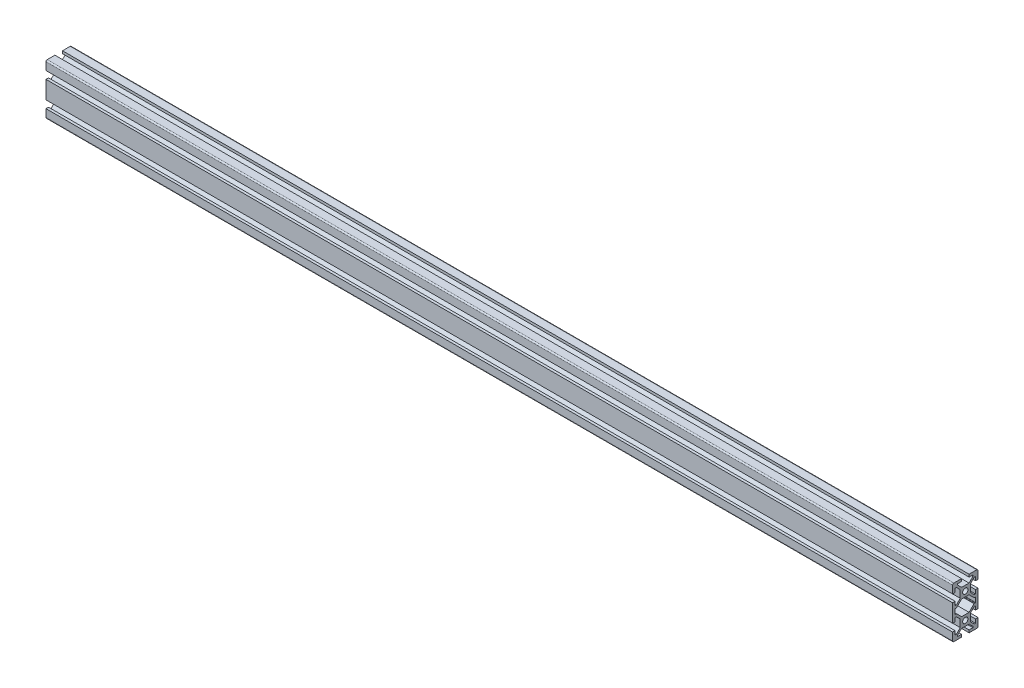
from build123d import *

# Parameters (mm, degrees)
SKETCH1_R           = 2.1
BOSS_EXTRUDE1_DEPTH = 714


with BuildPart() as part:
    # Sketch1 → Boss-Extrude1 (new body)
    with BuildSketch(Plane(origin=(0, 0, 0), x_dir=(0, 0, -1), z_dir=(1, 0, 0))):
        with BuildLine():
            Line((-10, -13), (-10, -19))
            ThreePointArc((-10, -19), (-9.707106781, -19.707106781), (-9, -20))
            Line((-9, -20), (-3, -20))
            Line((-3, -20), (-3, -18))
            Line((-3, -18), (-6, -18))
            Line((-6, -18), (-6, -17.060660172))
            Line((-6, -17.060660172), (-2.939339828, -14))
            Line((-2.939339828, -14), (2.939339828, -14))
            Line((2.939339828, -14), (6, -17.060660172))
            Line((6, -17.060660172), (6, -18))
            Line((6, -18), (3, -18))
            Line((3, -18), (3, -20))
            Line((3, -20), (9, -20))
            ThreePointArc((9, -20), (9.707106781, -19.707106781), (10, -19))
            Line((10, -19), (10, -13))
            Line((10, -13), (8, -13))
            Line((8, -13), (8, -16))
            Line((8, -16), (7.060660172, -16))
            Line((7.060660172, -16), (4, -12.939339828))
            Line((4, -12.939339828), (4, -7.060660172))
            Line((4, -7.060660172), (7.060660172, -4))
            Line((7.060660172, -4), (8, -4))
            Line((8, -4), (8, -7))
            Line((8, -7), (10, -7))
            Line((10, -7), (10, 7))
            Line((10, 7), (8, 7))
            Line((8, 7), (8, 4))
            Line((8, 4), (7.060660172, 4))
            Line((7.060660172, 4), (4, 7.060660172))
            Line((4, 7.060660172), (4, 12.939339828))
            Line((4, 12.939339828), (7.060660172, 16))
            Line((7.060660172, 16), (8, 16))
            Line((8, 16), (8, 13))
            Line((8, 13), (10, 13))
            Line((10, 13), (10, 19))
            ThreePointArc((10, 19), (9.707106781, 19.707106781), (9, 20))
            Line((9, 20), (3, 20))
            Line((3, 20), (3, 18))
            Line((3, 18), (6, 18))
            Line((6, 18), (6, 17.060660172))
            Line((6, 17.060660172), (2.939339828, 14))
            Line((2.939339828, 14), (-2.939339828, 14))
            Line((-2.939339828, 14), (-6, 17.060660172))
            Line((-6, 17.060660172), (-6, 18))
            Line((-6, 18), (-3, 18))
            Line((-3, 18), (-3, 20))
            Line((-3, 20), (-9, 20))
            ThreePointArc((-9, 20), (-9.707106781, 19.707106781), (-10, 19))
            Line((-10, 19), (-10, 13))
            Line((-10, 13), (-8, 13))
            Line((-8, 13), (-8, 16))
            Line((-8, 16), (-7.060660172, 16))
            Line((-7.060660172, 16), (-4, 12.939339828))
            Line((-4, 12.939339828), (-4, 7.060660172))
            Line((-4, 7.060660172), (-7.060660172, 4))
            Line((-7.060660172, 4), (-8, 4))
            Line((-8, 4), (-8, 7))
            Line((-8, 7), (-10, 7))
            Line((-10, 7), (-10, -7))
            Line((-10, -7), (-8, -7))
            Line((-8, -7), (-8, -4))
            Line((-8, -4), (-7.060660172, -4))
            Line((-7.060660172, -4), (-4, -7.060660172))
            Line((-4, -7.060660172), (-4, -12.939339828))
            Line((-4, -12.939339828), (-7.060660172, -16))
            Line((-7.060660172, -16), (-8, -16))
            Line((-8, -16), (-8, -13))
            Line((-8, -13), (-10, -13))
        make_face()
        with Locations((0, 10)):
            Circle(SKETCH1_R, mode=Mode.SUBTRACT)
        with Locations((0, -10)):
            Circle(SKETCH1_R, mode=Mode.SUBTRACT)
        with BuildLine():
            Line((-8, 1.7), (-8, -1.7))
            ThreePointArc((-8, -1.7), (-7.912132034, -1.912132034), (-7.7, -2))
            Line((-7.7, -2), (-7.063603897, -2))
            ThreePointArc((-7.063603897, -2), (-6.948798867, -2.02283614), (-6.851471863, -2.087867966))
            Line((-6.851471863, -2.087867966), (-2.939339828, -6))
            Line((-2.939339828, -6), (2.939339828, -6))
            Line((2.939339828, -6), (6.851471863, -2.087867966))
            ThreePointArc((6.851471863, -2.087867966), (6.948798867, -2.02283614), (7.063603897, -2))
            Line((7.063603897, -2), (7.7, -2))
            ThreePointArc((7.7, -2), (7.912132034, -1.912132034), (8, -1.7))
            Line((8, -1.7), (8, 1.7))
            ThreePointArc((8, 1.7), (7.912132034, 1.912132034), (7.7, 2))
            Line((7.7, 2), (7.063603897, 2))
            ThreePointArc((7.063603897, 2), (6.948798867, 2.02283614), (6.851471863, 2.087867966))
            Line((6.851471863, 2.087867966), (2.939339828, 6))
            Line((2.939339828, 6), (-2.939339828, 6))
            Line((-2.939339828, 6), (-6.851471863, 2.087867966))
            ThreePointArc((-6.851471863, 2.087867966), (-6.948798867, 2.02283614), (-7.063603897, 2))
            Line((-7.063603897, 2), (-7.7, 2))
            ThreePointArc((-7.7, 2), (-7.912132034, 1.912132034), (-8, 1.7))
        make_face(mode=Mode.SUBTRACT)
    extrude(amount=BOSS_EXTRUDE1_DEPTH)


solid = part.part
